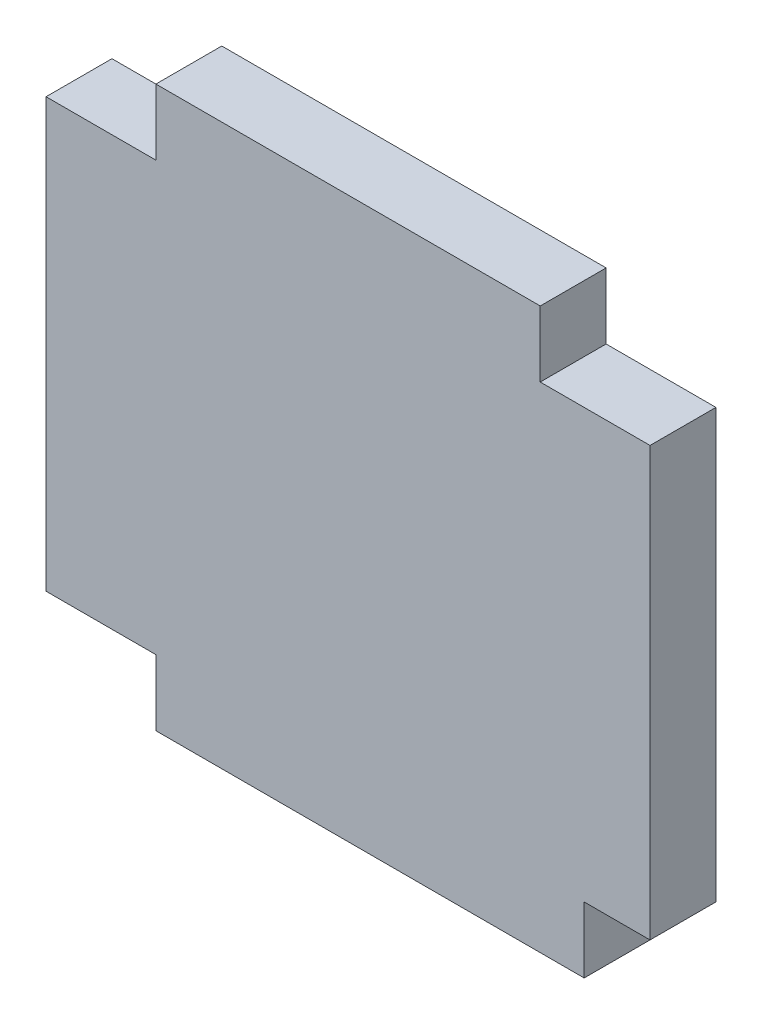
from build123d import *

# Parameters (mm, degrees)
BOSS_EXTRUDE1_DEPTH = 6
SKETCH2_W           = 10
SKETCH2_H           = 6
CUT_EXTRUDE1_DEPTH  = 6


with BuildPart() as part:
    # Sketch1 → Boss-Extrude1 (new body)
    with BuildSketch(Plane.XY):
        Polygon((0, 45), (55, 45), (55, 0), (49, 0), (49, -6), (10, -6), (10, 0), (0, 0), align=None)
    extrude(amount=BOSS_EXTRUDE1_DEPTH)

    # Sketch2 → Cut-Extrude1 (cut)
    with BuildSketch(Plane.XY.offset(6)):
        with Locations((5, 42)):
            Rectangle(SKETCH2_W, SKETCH2_H)
        with Locations((50, 42)):
            Rectangle(SKETCH2_W, SKETCH2_H)
    extrude(amount=-CUT_EXTRUDE1_DEPTH, mode=Mode.SUBTRACT)


solid = part.part
